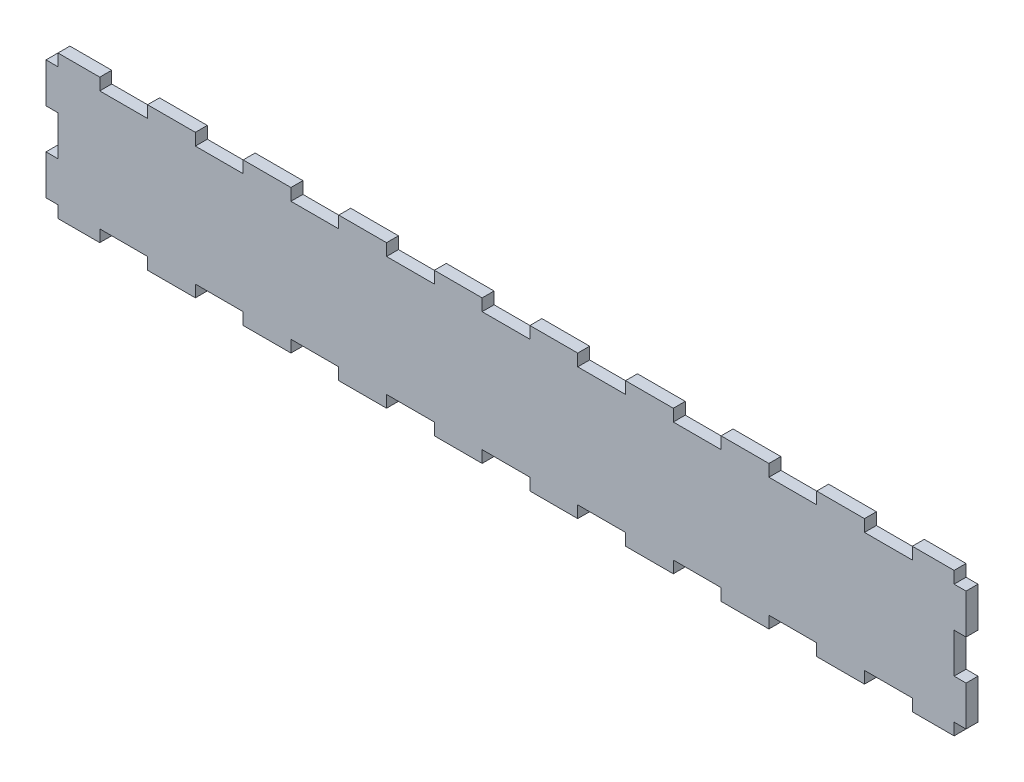
from build123d import *

# Parameters (mm, degrees)
BOSS_EXTRUDE1_DEPTH = 6
SKETCH3_W           = 6
SKETCH3_H           = 20
BOSS_EXTRUDE2_DEPTH = 6


with BuildPart() as part:
    # Sketch1 → Boss-Extrude1 (new body)
    with BuildSketch(Plane.XY):
        Polygon((-225, 0), (-204, 0), (-204, 6), (-180, 6), (-180, 0), (-156, 0), (-156, 6), (-132, 6), (-132, 0), (-108, 0), (-108, 6), (-84, 6), (-84, 0), (-60, 0), (-60, 6), (-36, 6), (-36, 0), (-12, 0), (-12, 6), (12, 6), (12, 0), (36, 0), (36, 6), (60, 6), (60, 0), (84, 0), (84, 6), (108, 6), (108, 0), (132, 0), (132, 6), (156, 6), (156, 0), (180, 0), (180, 6), (204, 6), (204, 0), (225, 0), (225, 72), (204, 72), (204, 66), (180, 66), (180, 72), (156, 72), (156, 66), (132, 66), (132, 72), (108, 72), (108, 66), (84, 66), (84, 72), (60, 72), (60, 66), (36, 66), (36, 72), (12, 72), (12, 66), (-12, 66), (-12, 72), (-36, 72), (-36, 66), (-60, 66), (-60, 72), (-84, 72), (-84, 66), (-108, 66), (-108, 72), (-132, 72), (-132, 66), (-156, 66), (-156, 72), (-180, 72), (-180, 66), (-204, 66), (-204, 72), (-225, 72), align=None)
    extrude(amount=BOSS_EXTRUDE1_DEPTH)

    # Sketch3 → Boss-Extrude2 (add)
    with BuildSketch(Plane.XY.offset(6)):
        with Locations((-228, 16)):
            Rectangle(SKETCH3_W, SKETCH3_H)
        with Locations((-228, 56)):
            Rectangle(SKETCH3_W, SKETCH3_H)
        with Locations((228, 16)):
            Rectangle(SKETCH3_W, SKETCH3_H)
        with Locations((228, 56)):
            Rectangle(SKETCH3_W, SKETCH3_H)
    extrude(amount=-BOSS_EXTRUDE2_DEPTH)


solid = part.part
